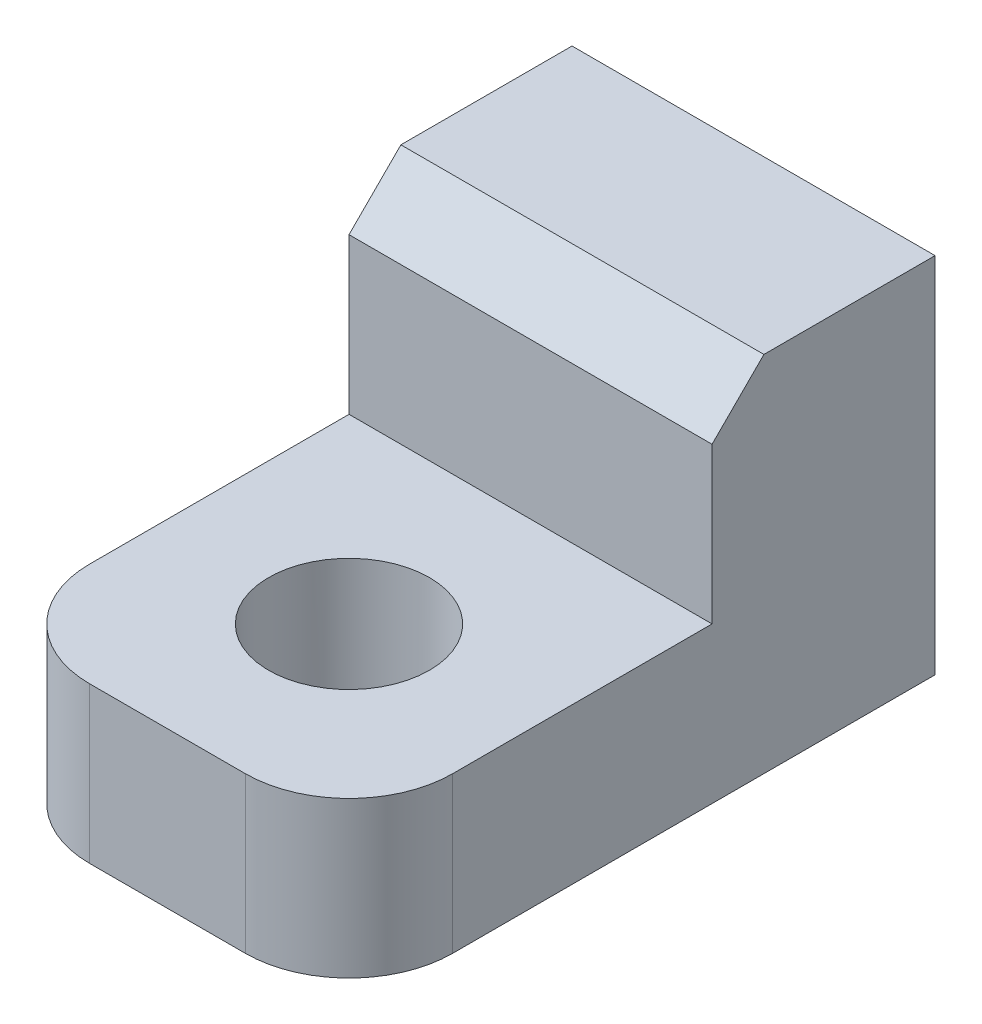
from build123d import *

# Parameters (mm, degrees)
SKETCH1_W           = 7
SKETCH1_H           = 7
SKETCH1_R           = 1.55
BOSS_EXTRUDE1_DEPTH = 2.3
SKETCH3_W           = 7
SKETCH3_H           = 7
BOSS_EXTRUDE2_DEPTH = 2
SKETCH4_W           = 7
SKETCH4_H           = 3
BOSS_EXTRUDE3_DEPTH = 7
CUT_EXTRUDE1_REACH  = 9
SKETCH5_R           = 1.55
FILLET1_R           = 2
CHAMFER1_SIZE       = 1


with BuildPart() as part:
    # Sketch1 → Boss-Extrude1 (new body)
    with BuildSketch(Plane.XY):
        with Locations((5, 6.5)):
            Rectangle(SKETCH1_W, SKETCH1_H)
        with Locations((5, 6.5)):
            Circle(SKETCH1_R, mode=Mode.SUBTRACT)
    extrude(amount=BOSS_EXTRUDE1_DEPTH)

    # Sketch3 → Boss-Extrude2 (add)
    with BuildSketch(Plane.XY.offset(2.3)):
        with Locations((5, 6.5)):
            Rectangle(SKETCH3_W, SKETCH3_H)
    extrude(amount=BOSS_EXTRUDE2_DEPTH)

    # Sketch4 → Boss-Extrude3 (add)
    with BuildSketch(Plane.XY.offset(4.3)):
        with Locations((5, 4.5)):
            Rectangle(SKETCH4_W, SKETCH4_H)
    extrude(amount=BOSS_EXTRUDE3_DEPTH)

    # Sketch5 → Cut-Extrude1 (cut, up to next)
    with BuildSketch(Plane.XZ.offset(-3), mode=Mode.PRIVATE) as cut_extrude1_sk1:
        with Locations((5, 7.8)):
            Circle(SKETCH5_R)
    cut_extrude1_tool1 = extrude(cut_extrude1_sk1.sketch, amount=-CUT_EXTRUDE1_REACH, mode=Mode.PRIVATE) & part.part
    add(cut_extrude1_tool1.solids().sort_by_distance((5, 3, 7.8))[0], mode=Mode.SUBTRACT)

    # Fillet1
    fillet1_edges = [part.edges().sort_by_distance(p)[0] for p in [
        (8.5, 4.5, 11.3),
        (1.5, 4.5, 11.3),
    ]]
    fillet(fillet1_edges, radius=FILLET1_R)

    # Chamfer1
    chamfer1_edges = [part.edges().sort_by_distance(p)[0] for p in [
        (5, 10, 4.3),
    ]]
    chamfer(chamfer1_edges, length=CHAMFER1_SIZE)


solid = part.part
